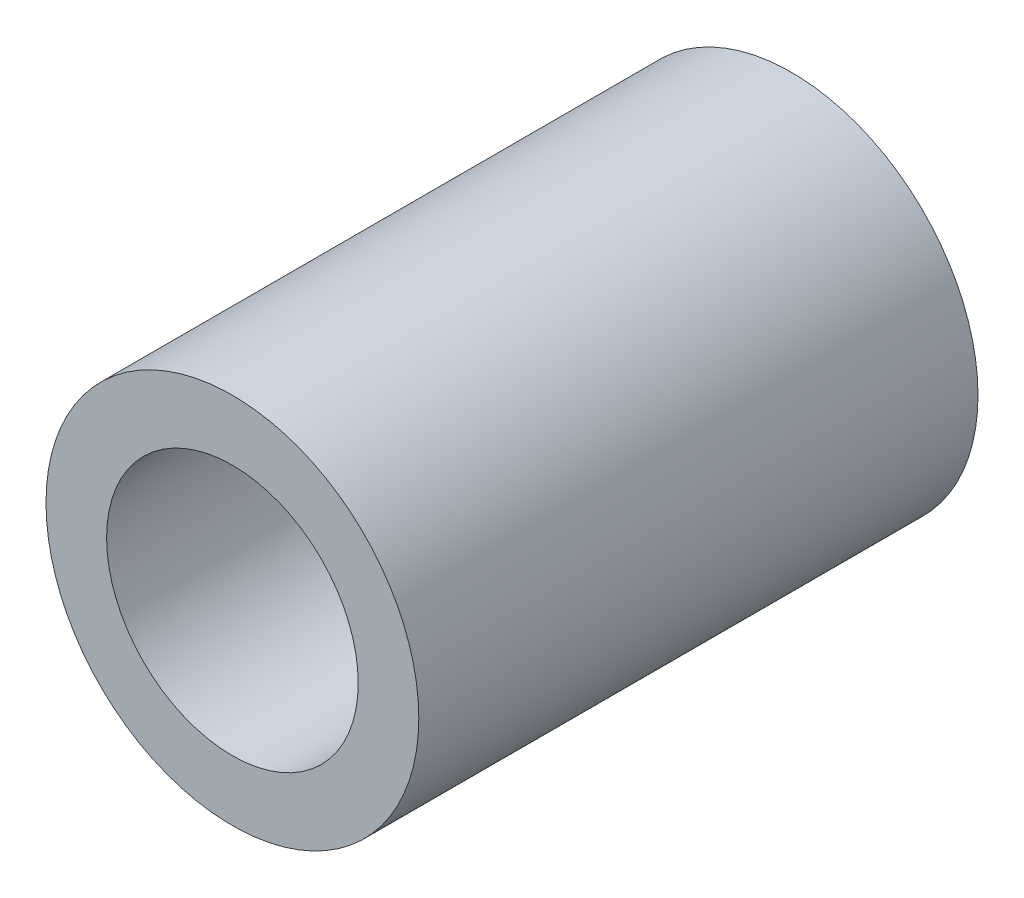
from build123d import *

# Parameters (mm, degrees)
CROQUIS1_R              = 2
CROQUIS1_R_2            = 1.35
SALIENTE_EXTRUIR1_DEPTH = 6


with BuildPart() as part:
    # Croquis1 → Saliente-Extruir1 (new body)
    with BuildSketch(Plane.XY):
        Circle(CROQUIS1_R)
        Circle(CROQUIS1_R_2, mode=Mode.SUBTRACT)
    extrude(amount=SALIENTE_EXTRUIR1_DEPTH)


solid = part.part
